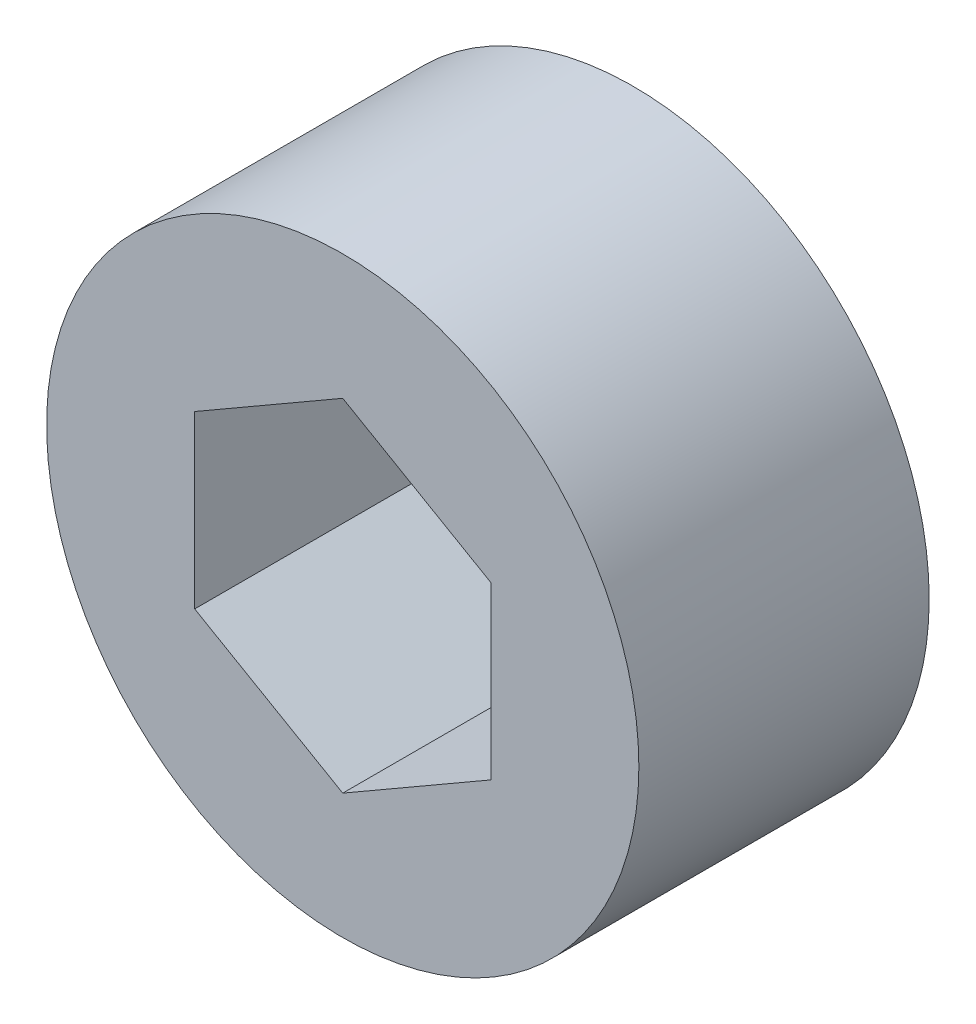
from build123d import *

# Parameters (mm, degrees)
SKETCH1_R           = 6.477
BOSS_EXTRUDE1_DEPTH = 6.35
CUT_EXTRUDE1_DEPTH  = 7.35


with BuildPart() as part:
    # Sketch1 → Boss-Extrude1 (new body)
    with BuildSketch(Plane.XY):
        Circle(SKETCH1_R)
    extrude(amount=BOSS_EXTRUDE1_DEPTH)

    # Sketch2 → Cut-Extrude1 (cut, through all)
    with BuildSketch(Plane.XY.offset(6.35)):
        Polygon((3.2385, 1.869748847), (0, 3.739497694), (-3.2385, 1.869748847), (-3.2385, -1.869748847), (0, -3.739497694), (3.2385, -1.869748847), align=None)
    extrude(amount=-CUT_EXTRUDE1_DEPTH, mode=Mode.SUBTRACT)


solid = part.part
